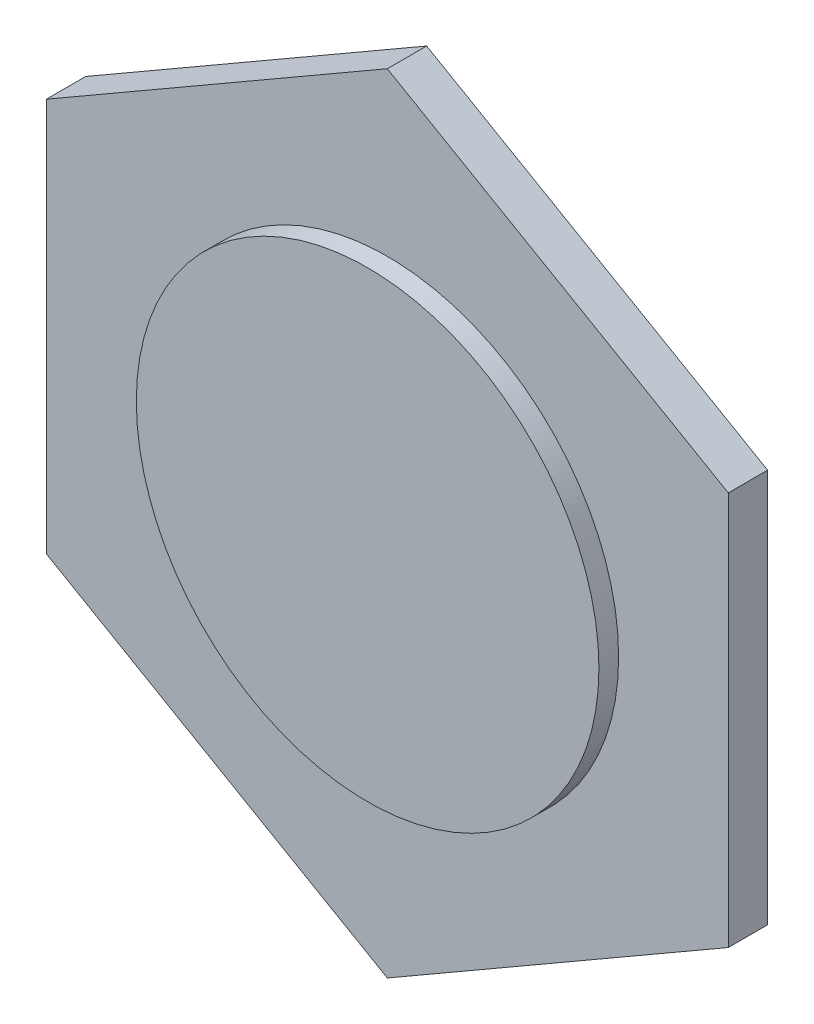
from build123d import *

# Parameters (mm, degrees)
SKETCH1_R           = 23.5
BOSS_EXTRUDE1_DEPTH = 4
SKETCH2_R           = 23.5
BOSS_EXTRUDE2_DEPTH = 6


with BuildPart() as part:
    # Sketch1 → Boss-Extrude1 (new body)
    with BuildSketch(Plane.XY):
        Polygon((34.641016151, 20), (0, 40), (-34.641016151, 20), (-34.641016151, -20), (0, -40), (34.641016151, -20), align=None)
        Circle(SKETCH1_R, mode=Mode.SUBTRACT)
    extrude(amount=BOSS_EXTRUDE1_DEPTH)

    # Sketch2 → Boss-Extrude2 (add)
    with BuildSketch(Plane.XY):
        Circle(SKETCH2_R)
    extrude(amount=BOSS_EXTRUDE2_DEPTH)


solid = part.part
